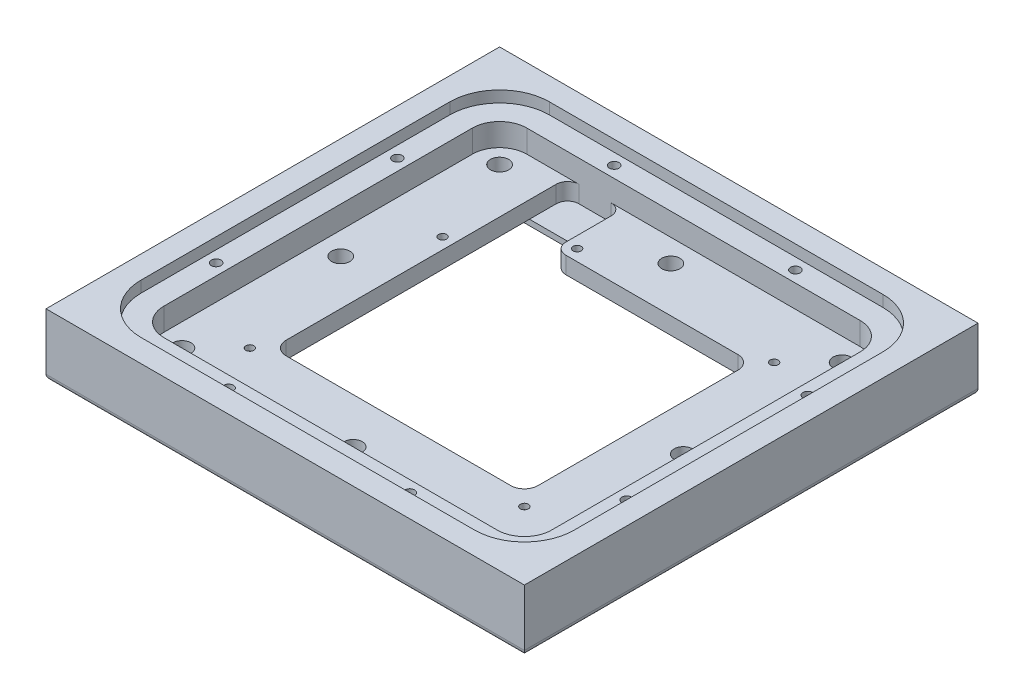
from build123d import *

# Parameters (mm, degrees)
SKETCH2_W                      = 134.112
SKETCH2_H                      = 127.1524
SKETCH2_W_2                    = 83.312
SKETCH2_H_2                    = 76.3524
SKETCH2_W_3                    = 21.7424
SKETCH2_H_3                    = 15.9766
BOSS_EXTRUDE1_DEPTH            = 15.875
BOSS_EXTRUDE2_DEPTH            = 9.525
CUT_EXTRUDE2_DEPTH             = 3.175
M2_5X0_45_TAPPED_HOLE1_D       = 2.05
M2_5X0_45_TAPPED_HOLE1_DEPTH   = 6.35
M2_5X0_45_TAPPED_HOLE1_TIP     = 0.615882135
F_10_CLEARANCE_HOLE1_D         = 5.1054
CUT_EXTRUDE3_DEPTH             = 6.35
CUT_EXTRUDE4_DEPTH             = 1.6
SKETCH12_W                     = 70.612
SKETCH12_H                     = 63.6524
CUT_EXTRUDE5_DEPTH             = 12.1
FILLET1_R                      = 3.81
SKETCH13_W                     = 134.112
SKETCH13_H                     = 127.1524
CUT_EXTRUDE6_DEPTH             = 1.5875
FILLET2_R                      = 1.5875
SKETCH14_W                     = 15.3924
SKETCH14_H                     = 22.86
CUT_EXTRUDE7_DEPTH             = 4.75
FILLET3_R                      = 3.175
SKETCH15_W                     = 134.112
SKETCH15_H                     = 127.1524
BOSS_EXTRUDE3_DEPTH            = 3.175
F_6_32_TAPPED_HOLE1_AT_2_COUNT = 2
F_6_32_TAPPED_HOLE1_AT_2_PITCH = 108.1024
F_6_32_TAPPED_HOLE1_AT_3_COUNT = 2
F_6_32_TAPPED_HOLE1_AT_3_PITCH = 85.702359025
F_6_32_TAPPED_HOLE1_AT_4_COUNT = 2
F_6_32_TAPPED_HOLE1_AT_4_PITCH = 43.049882955
SKETCH19_R                     = 2.7813
CUT_EXTRUDE8_DEPTH             = 3.175
F_4_40_TAPPED_HOLE1_D          = 2.2606
F_4_40_TAPPED_HOLE1_DEPTH      = 7.62
F_4_40_TAPPED_HOLE1_TIP        = 0.679152758


with BuildPart() as part:
    # Sketch2 → Boss-Extrude1 (new body)
    with BuildSketch(Plane(origin=(0, 0, 0), x_dir=(1, 0, 0), z_dir=(0, 1, 0))):
        Rectangle(SKETCH2_W, SKETCH2_H)
        Rectangle(SKETCH2_W_2, SKETCH2_H_2, mode=Mode.SUBTRACT)
        with Locations((-30.7848, 30.1879)):
            Rectangle(SKETCH2_W_3, SKETCH2_H_3)
    extrude(amount=BOSS_EXTRUDE1_DEPTH)

    # Sketch4 → Boss-Extrude2 (add)
    with BuildSketch(Plane(origin=(0, 0, 0), x_dir=(1, 0, 0), z_dir=(0, 1, 0))):
        Polygon((41.656, -38.1762), (41.656, 38.1762), (-19.9136, 38.1762), (-19.9136, 22.1996), (-41.656, 22.1996), (-41.656, -38.1762), align=None)
        Polygon((35.306, 31.8262), (-13.5636, 31.8262), (-13.5636, 15.8496), (-35.306, 15.8496), (-35.306, -31.8262), (35.306, -31.8262), align=None, mode=Mode.SUBTRACT)
    extrude(amount=BOSS_EXTRUDE2_DEPTH)

    # Sketch5 → Cut-Extrude2 (cut)
    with BuildSketch(Plane.XZ):
        with BuildLine():
            Line((46.736, -50.8762), (-46.736, -50.8762))
            ThreePointArc((-46.736, -50.8762), (-52.124153673, -48.644353673), (-54.356, -43.2562))
            Line((-54.356, -43.2562), (-54.356, 43.2562))
            ThreePointArc((-54.356, 43.2562), (-52.124153673, 48.644353673), (-46.736, 50.8762))
            Line((-46.736, 50.8762), (46.736, 50.8762))
            ThreePointArc((46.736, 50.8762), (52.124153673, 48.644353673), (54.356, 43.2562))
            Line((54.356, 43.2562), (54.356, -43.2562))
            ThreePointArc((54.356, -43.2562), (52.124153673, -48.644353673), (46.736, -50.8762))
        make_face()
    extrude(amount=-CUT_EXTRUDE2_DEPTH, mode=Mode.SUBTRACT)

    # M2.5x0.45 Tapped Hole1
    with Locations(Plane(origin=(0, 3.175, 0), x_dir=(-1, 0, 0), z_dir=(0, -1, 0))):
        with Locations((38.481, -35.0012), (-38.481, -35.0012), (38.481, 19.0246), (16.7386, 35.0012), (-38.481, 35.0012)):
            Hole(M2_5X0_45_TAPPED_HOLE1_D / 2, depth=M2_5X0_45_TAPPED_HOLE1_DEPTH)
            with Locations((0, 0, -(M2_5X0_45_TAPPED_HOLE1_DEPTH + M2_5X0_45_TAPPED_HOLE1_TIP / 2))):  # 118° drill point
                Cone(0, M2_5X0_45_TAPPED_HOLE1_D / 2, M2_5X0_45_TAPPED_HOLE1_TIP, mode=Mode.SUBTRACT)

    # #10 Clearance Hole1 (through all)
    with Locations(Plane(origin=(0, 3.175, 0), x_dir=(-1, 0, 0), z_dir=(0, -1, 0))):
        with Locations((48.006, -44.5262), (0, -44.5262), (-48.006, -44.5262), (-48.006, 0), (-48.006, 44.5262), (0, 44.5262), (48.006, 44.5262), (48.006, 0)):
            Hole(F_10_CLEARANCE_HOLE1_D / 2)

    # Sketch10 → Cut-Extrude3 (cut)
    with BuildSketch(Plane(origin=(0, 15.875, 0), x_dir=(1, 0, 0), z_dir=(0, 1, 0))):
        with BuildLine():
            Line((54.356, -43.2562), (54.356, 43.2562))
            ThreePointArc((54.356, 43.2562), (52.124153673, 48.644353673), (46.736, 50.8762))
            Line((46.736, 50.8762), (-46.736, 50.8762))
            ThreePointArc((-46.736, 50.8762), (-52.124153673, 48.644353673), (-54.356, 43.2562))
            Line((-54.356, 43.2562), (-54.356, -43.2562))
            ThreePointArc((-54.356, -43.2562), (-52.124153673, -48.644353673), (-46.736, -50.8762))
            Line((-46.736, -50.8762), (46.736, -50.8762))
            ThreePointArc((46.736, -50.8762), (52.124153673, -48.644353673), (54.356, -43.2562))
        make_face()
    extrude(amount=-CUT_EXTRUDE3_DEPTH, mode=Mode.SUBTRACT)

    # Sketch11 → Cut-Extrude4 (cut)
    with BuildSketch(Plane.XZ.offset(-3.175)):
        with BuildLine():
            Line((40.513, 40.2082), (-40.513, 40.2082))
            ThreePointArc((-40.513, 40.2082), (-42.75806403, 39.27826403), (-43.688, 37.0332))
            Line((-43.688, 37.0332), (-43.688, -37.0332))
            ThreePointArc((-43.688, -37.0332), (-42.75806403, -39.27826403), (-40.513, -40.2082))
            Line((-40.513, -40.2082), (40.513, -40.2082))
            ThreePointArc((40.513, -40.2082), (42.75806403, -39.27826403), (43.688, -37.0332))
            Line((43.688, -37.0332), (43.688, 37.0332))
            ThreePointArc((43.688, 37.0332), (42.75806403, 39.27826403), (40.513, 40.2082))
        make_face()
    extrude(amount=-CUT_EXTRUDE4_DEPTH, mode=Mode.SUBTRACT)

    # Sketch12 → Cut-Extrude5 (cut, through all)
    with BuildSketch(Plane.XZ.offset(-4.775)):
        Rectangle(SKETCH12_W, SKETCH12_H)
    extrude(amount=-CUT_EXTRUDE5_DEPTH, mode=Mode.SUBTRACT)

    # Fillet1
    fillet1_edges = [part.edges().sort_by_distance(p)[0] for p in [
        (-35.306, 7.15, -31.8262),
        (35.306, 7.15, -31.8262),
        (-35.306, 7.15, 31.8262),
        (35.306, 7.15, 31.8262),
    ]]
    fillet(fillet1_edges, radius=FILLET1_R)

    # Sketch13 → Cut-Extrude6 (cut)
    with BuildSketch(Plane.XZ):
        Rectangle(SKETCH13_W, SKETCH13_H)
        with BuildLine():
            Line((54.356, -43.2562), (54.356, 43.2562))
            ThreePointArc((54.356, 43.2562), (52.124153673, 48.644353673), (46.736, 50.8762))
            Line((46.736, 50.8762), (-46.736, 50.8762))
            ThreePointArc((-46.736, 50.8762), (-52.124153673, 48.644353673), (-54.356, 43.2562))
            Line((-54.356, 43.2562), (-54.356, -43.2562))
            ThreePointArc((-54.356, -43.2562), (-52.124153673, -48.644353673), (-46.736, -50.8762))
            Line((-46.736, -50.8762), (46.736, -50.8762))
            ThreePointArc((46.736, -50.8762), (52.124153673, -48.644353673), (54.356, -43.2562))
        make_face(mode=Mode.SUBTRACT)
    extrude(amount=-CUT_EXTRUDE6_DEPTH, mode=Mode.SUBTRACT)

    # Fillet2
    fillet2_edges = [part.edges().sort_by_distance(p)[0] for p in [
        (67.056, 1.5875, 0),
        (0, 1.5875, -63.5762),
        (-67.056, 1.5875, 0),
        (0, 1.5875, 63.5762),
    ]]
    fillet(fillet2_edges, radius=FILLET2_R)

    # Sketch14 → Cut-Extrude7 (cut)
    with BuildSketch(Plane(origin=(0, 9.525, 0), x_dir=(1, 0, 0), z_dir=(0, 1, 0))):
        with Locations((-27.6098, 39.4462)):
            Rectangle(SKETCH14_W, SKETCH14_H)
    extrude(amount=-CUT_EXTRUDE7_DEPTH, mode=Mode.SUBTRACT)

    # Fillet3
    fillet3_edges = [part.edges().sort_by_distance(p)[0] for p in [
        (-19.9136, 7.15, -31.8262),
        (-19.9136, 7.15, -50.8762),
        (-35.306, 7.15, -50.8762),
    ]]
    fillet(fillet3_edges, radius=FILLET3_R)

    # Sketch15 → Boss-Extrude3 (add)
    with BuildSketch(Plane(origin=(0, 15.875, 0), x_dir=(1, 0, 0), z_dir=(0, 1, 0))):
        Rectangle(SKETCH15_W, SKETCH15_H)
        with BuildLine():
            ThreePointArc((46.736, -57.2262), (56.614281733, -53.134481733), (60.706, -43.2562))
            Line((60.706, -43.2562), (60.706, 43.2562))
            ThreePointArc((60.706, 43.2562), (56.614281733, 53.134481733), (46.736, 57.2262))
            Line((46.736, 57.2262), (-46.736, 57.2262))
            ThreePointArc((-46.736, 57.2262), (-56.614281733, 53.134481733), (-60.706, 43.2562))
            Line((-60.706, 43.2562), (-60.706, -43.2562))
            ThreePointArc((-60.706, -43.2562), (-56.614281733, -53.134481733), (-46.736, -57.2262))
            Line((-46.736, -57.2262), (46.736, -57.2262))
        make_face(mode=Mode.SUBTRACT)
    extrude(amount=BOSS_EXTRUDE3_DEPTH)

    # Sketch18 → #6-32 Tapped Hole1 (revolve, cut)
    with BuildSketch(Plane(origin=(-25.4, 15.875, 54.0512), x_dir=(0, 0, 1), z_dir=(1, 0, 0))):
        Polygon((0, 0), (0, 10.33769403), (1.35255, 9.525), (1.35255, 0), align=None)
    f_6_32_tapped_hole1 = revolve(axis=Axis((-25.4, 22.225, 54.0512), (0, -1, 0)), mode=Mode.SUBTRACT)

    # #6-32 Tapped Hole1 at 2: #6-32 Tapped Hole1 ×2
    with Locations(*[(0, 0, -i * F_6_32_TAPPED_HOLE1_AT_2_PITCH) for i in range(1, F_6_32_TAPPED_HOLE1_AT_2_COUNT)]):
        add(f_6_32_tapped_hole1, mode=Mode.SUBTRACT)

    # #6-32 Tapped Hole1 at 3: #6-32 Tapped Hole1 ×2
    with Locations(*[Vector(-0.374913834, 0, -0.927059662) * (i * F_6_32_TAPPED_HOLE1_AT_3_PITCH) for i in range(1, F_6_32_TAPPED_HOLE1_AT_3_COUNT)]):
        add(f_6_32_tapped_hole1, mode=Mode.SUBTRACT)

    # #6-32 Tapped Hole1 at 4: #6-32 Tapped Hole1 ×2
    with Locations(*[Vector(-0.746366721, 0, -0.665534911) * (i * F_6_32_TAPPED_HOLE1_AT_4_PITCH) for i in range(1, F_6_32_TAPPED_HOLE1_AT_4_COUNT)]):
        add(f_6_32_tapped_hole1, mode=Mode.SUBTRACT)

    # Mirror1: #6-32 Tapped Hole1 across plane
    add(f_6_32_tapped_hole1.mirror(Plane(origin=(0, 0, 0), x_dir=(0, 0, 1), z_dir=(1, 0, 0))), mode=Mode.SUBTRACT)

    # Mirror1 copy 1 sketch → Mirror1 copy 1 (revolve, cut)
    with BuildSketch(Plane(origin=(25.4, 15.875, -54.0512), x_dir=(0, 0, 1), z_dir=(-1, 0, 0))):
        Polygon((0, 0), (0, -10.33769403), (1.35255, -9.525), (1.35255, 0), align=None)
    revolve(axis=Axis((25.4, 22.225, -54.0512), (0, 1, 0)), mode=Mode.SUBTRACT)

    # Mirror1 copy 2 sketch → Mirror1 copy 2 (revolve, cut)
    with BuildSketch(Plane(origin=(57.531, 15.875, -25.4), x_dir=(0, 0, 1), z_dir=(-1, 0, 0))):
        Polygon((0, 0), (0, -10.33769403), (1.35255, -9.525), (1.35255, 0), align=None)
    revolve(axis=Axis((57.531, 22.225, -25.4), (0, 1, 0)), mode=Mode.SUBTRACT)

    # Mirror1 copy 3 sketch → Mirror1 copy 3 (revolve, cut)
    with BuildSketch(Plane(origin=(57.531, 15.875, 25.4), x_dir=(0, 0, 1), z_dir=(-1, 0, 0))):
        Polygon((0, 0), (0, -10.33769403), (1.35255, -9.525), (1.35255, 0), align=None)
    revolve(axis=Axis((57.531, 22.225, 25.4), (0, 1, 0)), mode=Mode.SUBTRACT)

    # Sketch19 → Cut-Extrude8 (cut)
    with BuildSketch(Plane.XZ.offset(-4.775)):
        with Locations((38.481, 35.0012)):
            Circle(SKETCH19_R)
        with Locations((38.481, -35.0012)):
            Circle(SKETCH19_R)
        with Locations((-38.481, 35.0012)):
            Circle(SKETCH19_R)
        with Locations((-38.481, -19.0246)):
            Circle(SKETCH19_R)
        with Locations((-16.7386, -35.0012)):
            Circle(SKETCH19_R)
    extrude(amount=-CUT_EXTRUDE8_DEPTH, mode=Mode.SUBTRACT)

    # #4-40 Tapped Hole1
    with Locations(Plane(origin=(0, 9.525, 0), x_dir=(1, 0, 0), z_dir=(0, 1, 0))):
        with Locations((-38.481, 19.0246), (-16.7386, 35.0012), (38.481, 35.0012), (38.481, -35.0012), (-38.481, -35.0012)):
            Hole(F_4_40_TAPPED_HOLE1_D / 2, depth=F_4_40_TAPPED_HOLE1_DEPTH)
            with Locations((0, 0, -(F_4_40_TAPPED_HOLE1_DEPTH + F_4_40_TAPPED_HOLE1_TIP / 2))):  # 118° drill point
                Cone(0, F_4_40_TAPPED_HOLE1_D / 2, F_4_40_TAPPED_HOLE1_TIP, mode=Mode.SUBTRACT)


solid = part.part
